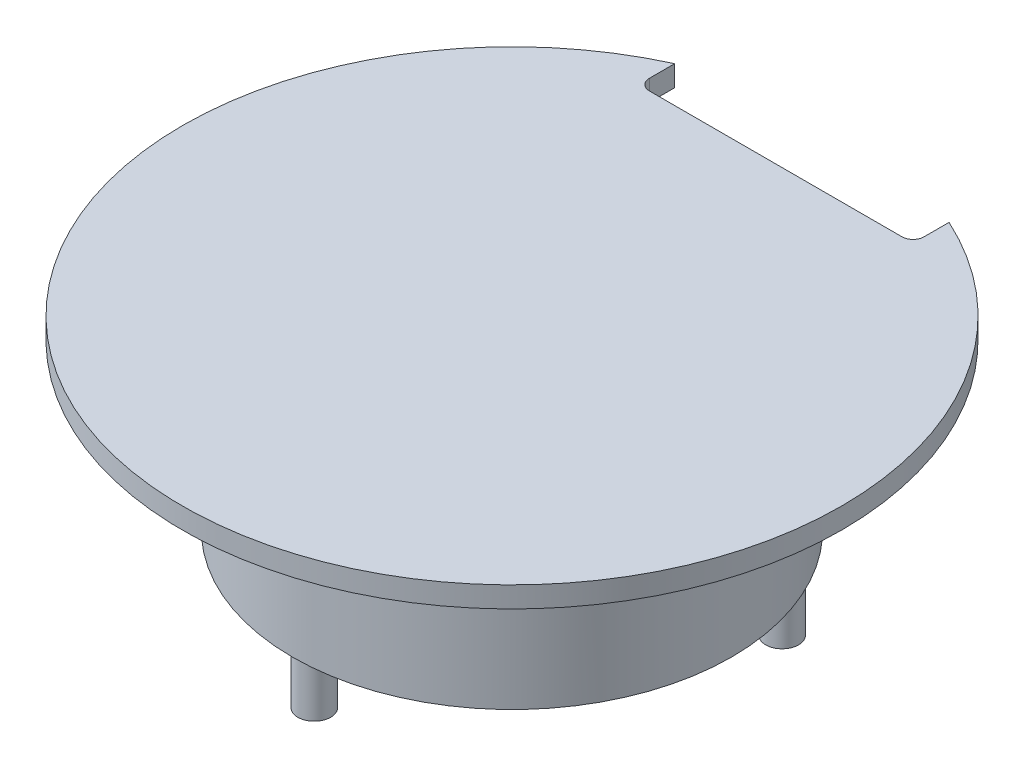
from build123d import *

# Parameters (mm, degrees)
SKETCH4_R               = 1.5
BOSS_EXTRUDE1_DEPTH     = 5
SKETCH5_W               = 25
SKETCH5_H               = 6.621086299
CUT_EXTRUDE5_DEPTH      = 5
FILLET1_R               = 1
CUT_EXTRUDE9_DEPTH      = 77.752708656
CUT_EXTRUDE9_DEPTH_BACK = 15
MOVE_FACE1_BY           = 0.1


with BuildPart() as part:
    # Sketch2 → Revolve3 (revolve)
    with BuildSketch(Plane.XY, mode=Mode.PRIVATE) as revolve3_sk:
        Polygon((1.5, -20), (1.5, -5), (11.5, -5), (11.5, -3.1), (-18.5, -3.1), (-18.5, -5.1), (-2.5, -5.1), (-2.5, -20), align=None)
    revolve(revolve3_sk.sketch.rotate(Axis((-18.5, -3.1, 0), (0, -1, 0)), 90), axis=Axis((-18.5, -3.1, 0), (0, -1, 0)))

    # Sketch4 → Boss-Extrude1 (add)
    with BuildSketch(Plane.XZ.offset(20)):
        with Locations(Location((-2.911542732, -9, 0), (0, 0, 90))):
            Circle(SKETCH4_R)
        with Locations(Location((-18.5, 18, 0), (0, 0, 90))):
            Circle(SKETCH4_R)
        with Locations(Location((-34.088457268, -9, 0), (0, 0, 90))):
            Circle(SKETCH4_R)
    extrude(amount=BOSS_EXTRUDE1_DEPTH)

    # Sketch5 → Cut-Extrude5 (cut)
    with BuildSketch(Plane(origin=(0, -3.1, 0), x_dir=(1, 0, 0), z_dir=(0, 1, 0))):
        with Locations((-18.475404108, 27.289504664)):
            Rectangle(SKETCH5_W, SKETCH5_H)
    extrude(amount=-CUT_EXTRUDE5_DEPTH, mode=Mode.SUBTRACT)

    # Fillet1
    fillet1_edges = [part.edges().sort_by_distance(p)[0] for p in [
        (-5.975404108, -4.05, -23.978961514),
        (-30.975404108, -4.05, -23.978961514),
    ]]
    fillet(fillet1_edges, radius=FILLET1_R)

    # Sketch6 → Cut-Extrude9 (cut, two sides)
    with BuildSketch(Plane(origin=(0, 0, -23.978961514), x_dir=(-1, 0, 0), z_dir=(0, 0, -1))) as cut_extrude9_sk:
        Polygon((18.487702054, -11.55), (18.478169327, -5), (9.487702054, -5), (9.487702054, -11.55), align=None)
        Polygon((27.487702054, -5), (18.478169327, -5), (18.487702054, -11.55), (27.487702054, -11.55), align=None)
    extrude(amount=CUT_EXTRUDE9_DEPTH, mode=Mode.SUBTRACT)
    extrude(cut_extrude9_sk.sketch, amount=-CUT_EXTRUDE9_DEPTH_BACK, mode=Mode.SUBTRACT)

    # Move Face1: a face moved inward by 0.1
    extrude(part.faces().sort_by_distance((-18.501355787, -5.1, 1.924560303))[0], amount=MOVE_FACE1_BY, dir=(0, 1, 0), mode=Mode.SUBTRACT)


solid = part.part
